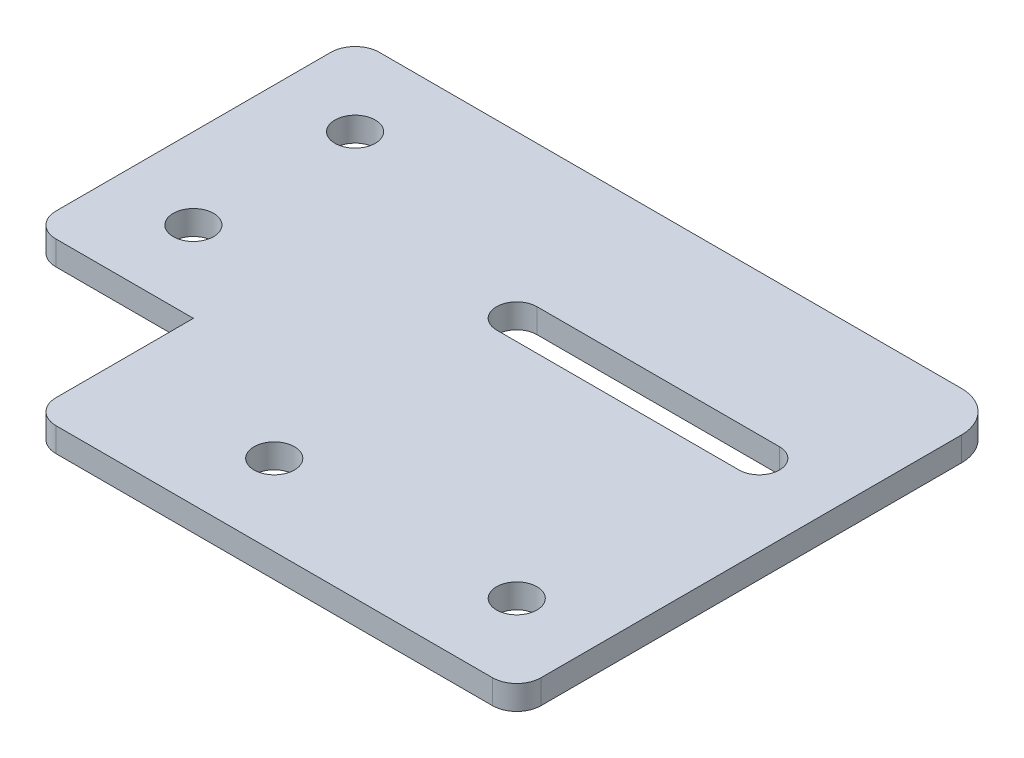
from build123d import *

# Parameters (mm, degrees)
SKETCH1_R           = 2.5
BOSS_EXTRUDE2_DEPTH = 3


with BuildPart() as part:
    # Sketch1 → Boss-Extrude2 (new body)
    with BuildSketch(Plane(origin=(0, 0, 0), x_dir=(1, 0, 0), z_dir=(0, 1, 0))):
        with BuildLine():
            Line((0, 19.583928173), (0, 53.583928173))
            ThreePointArc((0, 53.583928173), (0.878679656, 55.705248517), (3, 56.583928173))
            Line((3, 56.583928173), (75, 56.583928173))
            ThreePointArc((75, 56.583928173), (78.535533906, 55.119462079), (80, 51.583928173))
            Line((80, 51.583928173), (80, -0.416071827))
            ThreePointArc((80, -0.416071827), (79.121320344, -2.537392171), (77, -3.416071827))
            Line((77, -3.416071827), (23, -3.416071827))
            ThreePointArc((23, -3.416071827), (20.878679656, -2.537392171), (20, -0.416071827))
            Line((20, -0.416071827), (20, 16.583928173))
            Line((20, 16.583928173), (3, 16.583928173))
            ThreePointArc((3, 16.583928173), (0.878679656, 17.462607829), (0, 19.583928173))
        make_face()
        with Locations((10, 26.583928173)):
            Circle(SKETCH1_R, mode=Mode.SUBTRACT)
        with Locations((40, 6.583928173)):
            Circle(SKETCH1_R, mode=Mode.SUBTRACT)
        with Locations((70, 6.583928173)):
            Circle(SKETCH1_R, mode=Mode.SUBTRACT)
        with Locations((10, 46.583928173)):
            Circle(SKETCH1_R, mode=Mode.SUBTRACT)
        with BuildLine():
            Line((40, 39.083928173), (70, 39.083928173))
            ThreePointArc((70, 39.083928173), (72.5, 36.583928173), (70, 34.083928173))
            Line((70, 34.083928173), (40, 34.083928173))
            ThreePointArc((40, 34.083928173), (37.5, 36.583928173), (40, 39.083928173))
        make_face(mode=Mode.SUBTRACT)
    extrude(amount=BOSS_EXTRUDE2_DEPTH)


solid = part.part
